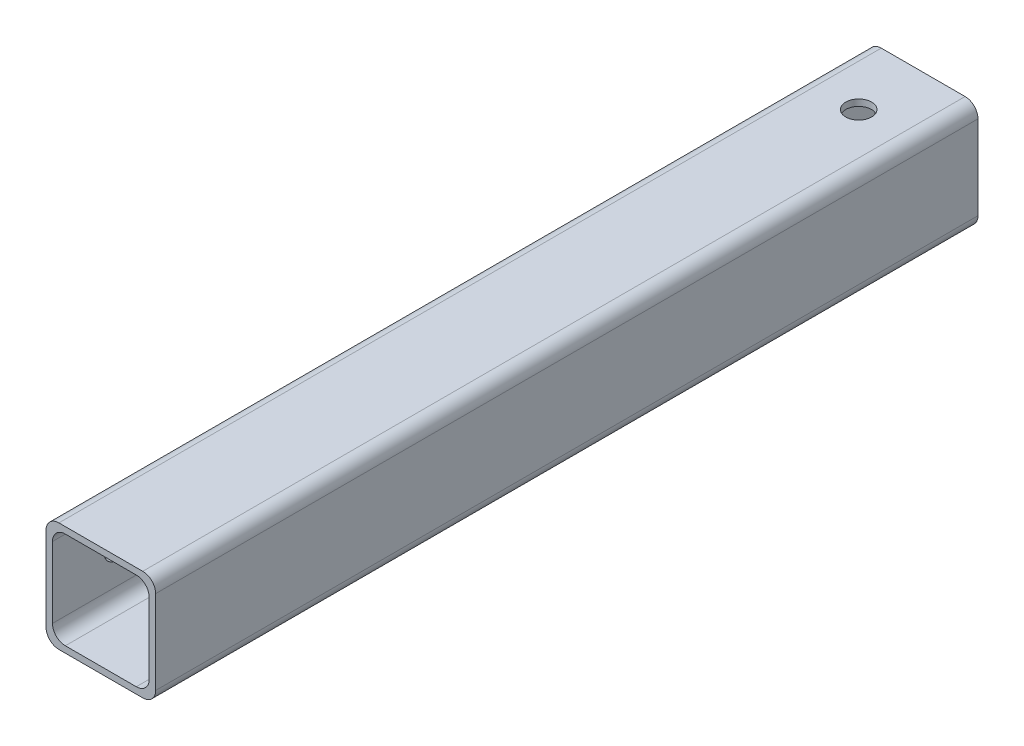
from build123d import *

# Parameters (mm, degrees)
SKETCH4_W                  = 21.59
SKETCH4_H                  = 21.59
SKETCH4_W_2                = 19.05
SKETCH4_H_2                = 19.05
BOSS_EXTRUDE2_DEPTH        = 161.925
FILLET1_R                  = 2.54
F_10_CLEARANCE_HOLE1_D     = 5.1054
F_10_CLEARANCE_HOLE1_DEPTH = 12.7
F_10_CLEARANCE_HOLE1_TIP   = 1.533816902
F_10_CLEARANCE_HOLE2_D     = 5.1054
F_10_CLEARANCE_HOLE2_DEPTH = 12.7
F_10_CLEARANCE_HOLE2_TIP   = 1.533816902


with BuildPart() as part:
    # Sketch4 → Boss-Extrude2 (new body)
    with BuildSketch(Plane.XY):
        Rectangle(SKETCH4_W, SKETCH4_H)
        Rectangle(SKETCH4_W_2, SKETCH4_H_2, mode=Mode.SUBTRACT)
    extrude(amount=BOSS_EXTRUDE2_DEPTH)

    # Fillet1
    fillet1_edges = [part.edges().sort_by_distance(p)[0] for p in [
        (-9.525, 9.525, 80.9625),
        (-9.525, -9.525, 80.9625),
        (9.525, -9.525, 80.9625),
        (9.525, 9.525, 80.9625),
        (-10.795, 10.795, 80.9625),
        (10.795, 10.795, 80.9625),
        (10.795, -10.795, 80.9625),
        (-10.795, -10.795, 80.9625),
    ]]
    fillet(fillet1_edges, radius=FILLET1_R)

    # #10 Clearance Hole1
    with Locations(Plane(origin=(0, 10.795, 0), x_dir=(1, 0, 0), z_dir=(0, 1, 0))):
        with Locations((0, -12.7)):
            Hole(F_10_CLEARANCE_HOLE1_D / 2, depth=F_10_CLEARANCE_HOLE1_DEPTH)
            with Locations((0, 0, -(F_10_CLEARANCE_HOLE1_DEPTH + F_10_CLEARANCE_HOLE1_TIP / 2))):  # 118° drill point
                Cone(0, F_10_CLEARANCE_HOLE1_D / 2, F_10_CLEARANCE_HOLE1_TIP, mode=Mode.SUBTRACT)

    # #10 Clearance Hole2
    with Locations(Plane.ZY.offset(10.795)):
        with Locations((149.225, 0)):
            Hole(F_10_CLEARANCE_HOLE2_D / 2, depth=F_10_CLEARANCE_HOLE2_DEPTH)
            with Locations((0, 0, -(F_10_CLEARANCE_HOLE2_DEPTH + F_10_CLEARANCE_HOLE2_TIP / 2))):  # 118° drill point
                Cone(0, F_10_CLEARANCE_HOLE2_D / 2, F_10_CLEARANCE_HOLE2_TIP, mode=Mode.SUBTRACT)


solid = part.part
